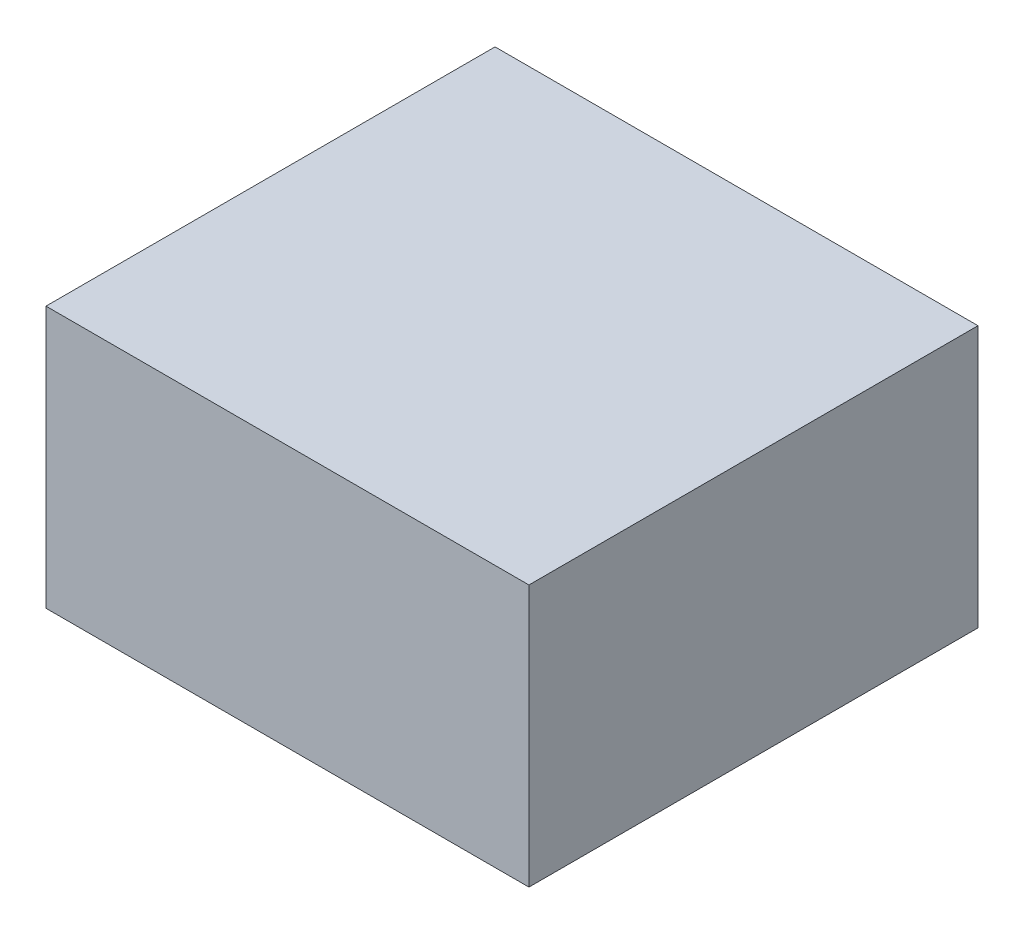
from build123d import *

# Parameters (mm, degrees)
SKETCH1_W      = 103.124
SKETCH1_H      = 95.885
EXTRUDE1_DEPTH = 55.88


with BuildPart() as part:
    # Sketch1 → Extrude1 (new body)
    with BuildSketch(Plane(origin=(0, 0, 0), x_dir=(1, 0, 0), z_dir=(0, 1, 0))):
        with Locations((51.562, -47.9425)):
            Rectangle(SKETCH1_W, SKETCH1_H)
    extrude(amount=EXTRUDE1_DEPTH)


solid = part.part
